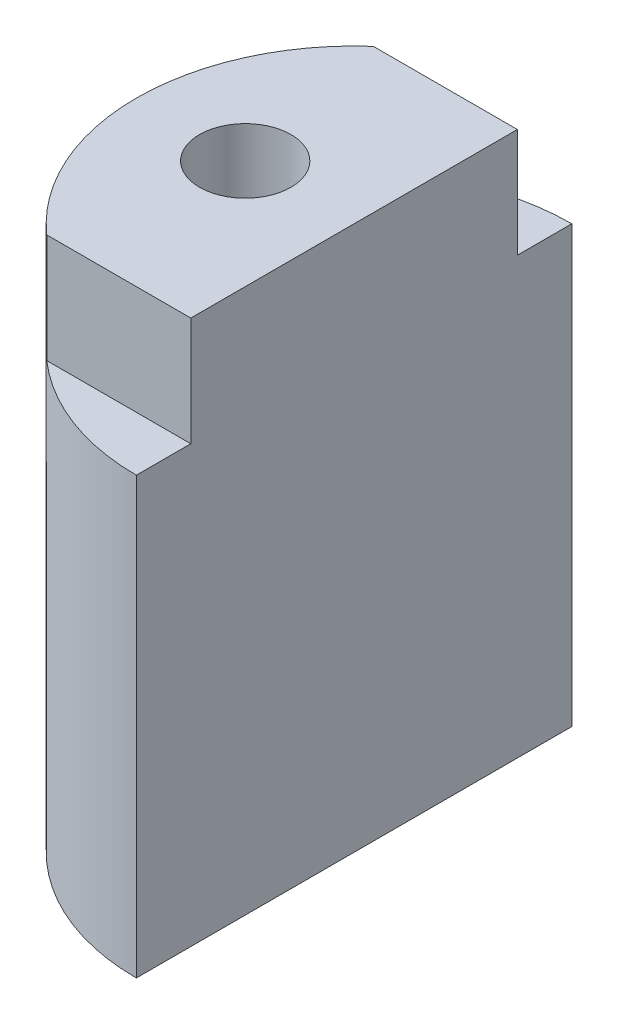
from build123d import *

# Parameters (mm, degrees)
BOSS_EXTRUDE1_DEPTH   = 25
CUT_EXTRUDE1_DEPTH    = 5
M5_TAPPED_HOLE1_D     = 4.2
M5_TAPPED_HOLE1_DEPTH = 11.1381927
M5_TAPPED_HOLE1_TIP   = 1.2618073


with BuildPart() as part:
    # Sketch1 → Boss-Extrude1 (new body)
    with BuildSketch(Plane(origin=(0, 0, 0), x_dir=(1, 0, 0), z_dir=(0, 1, 0))):
        with BuildLine():
            Line((0, 10), (0, -10))
            ThreePointArc((0, -10), (-10, 0), (0, 10))
        make_face()
    extrude(amount=BOSS_EXTRUDE1_DEPTH)

    # Sketch18 → Cut-Extrude1 (cut)
    with BuildSketch(Plane(origin=(0, 25, 0), x_dir=(1, 0, 0), z_dir=(0, 1, 0))):
        with BuildLine():
            Line((0, 7.5), (0, 10))
            ThreePointArc((0, 10), (-3.535533906, 9.354143467), (-6.614378278, 7.5))
            Line((-6.614378278, 7.5), (0, 7.5))
        make_face()
        with BuildLine():
            Line((0, -10), (0, -7.5))
            Line((0, -7.5), (-6.614378278, -7.5))
            ThreePointArc((-6.614378278, -7.5), (-3.535533906, -9.354143467), (0, -10))
        make_face()
    extrude(amount=-CUT_EXTRUDE1_DEPTH, mode=Mode.SUBTRACT)

    # M5 Tapped Hole1
    with Locations(Plane(origin=(0, 25, 0), x_dir=(1, 0, 0), z_dir=(0, 1, 0))):
        with Locations((-5, 0)):
            Hole(M5_TAPPED_HOLE1_D / 2, depth=M5_TAPPED_HOLE1_DEPTH)
            with Locations((0, 0, -(M5_TAPPED_HOLE1_DEPTH + M5_TAPPED_HOLE1_TIP / 2))):  # 118° drill point
                Cone(0, M5_TAPPED_HOLE1_D / 2, M5_TAPPED_HOLE1_TIP, mode=Mode.SUBTRACT)


solid = part.part
